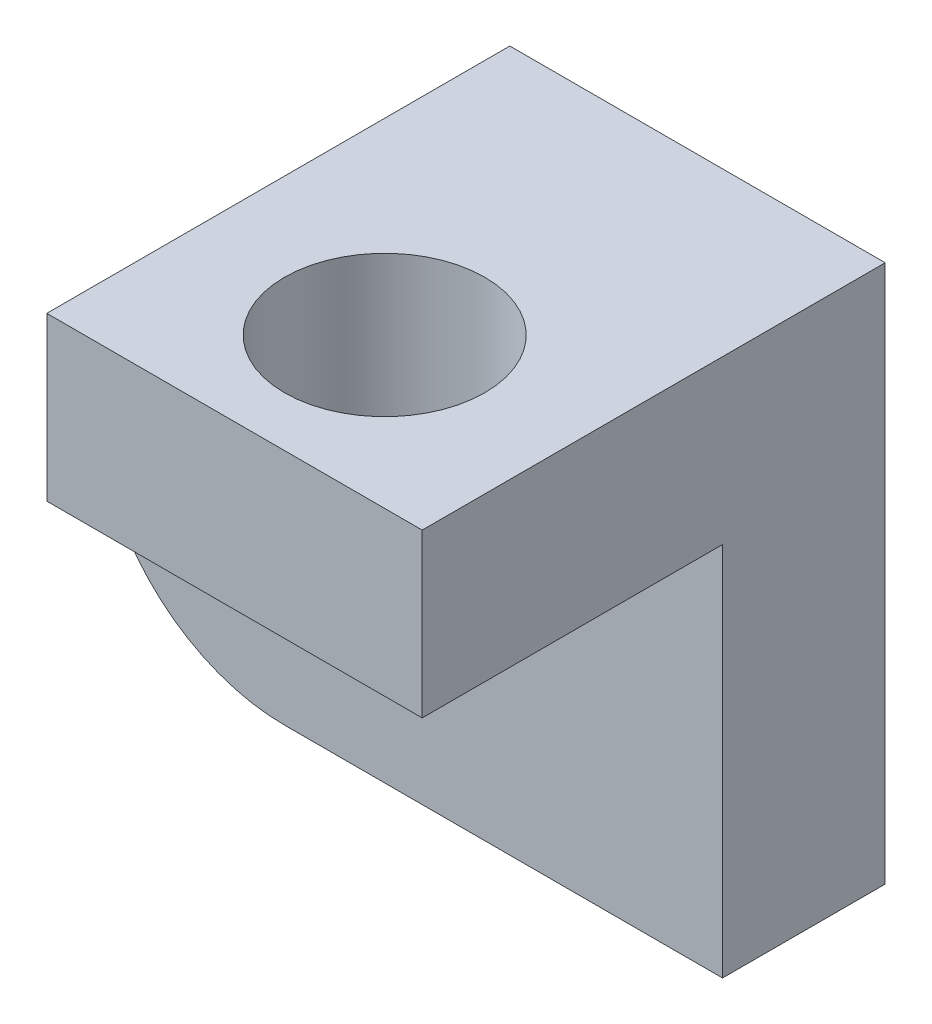
from build123d import *

# Parameters (mm, degrees)
SKETCH1_R           = 6.5
BOSS_EXTRUDE1_DEPTH = 13
SKETCH3_W           = 30
SKETCH3_H           = 13
BOSS_EXTRUDE2_DEPTH = 13
SKETCH6_W           = 30
SKETCH6_H           = 13
BOSS_EXTRUDE4_DEPTH = 24
SKETCH7_R           = 8
CUT_EXTRUDE1_DEPTH  = 13


with BuildPart() as part:
    # Sketch1 → Boss-Extrude1 (new body)
    with BuildSketch(Plane.XY):
        with BuildLine():
            Line((-54.326139095, 0), (-19.326139095, 0))
            Line((-19.326139095, 0), (-19.326139095, 30))
            Line((-19.326139095, 30), (-54.326139095, 30))
            ThreePointArc((-54.326139095, 30), (-69.326139095, 15), (-54.326139095, 0))
        make_face()
        with Locations((-54.326139095, 15)):
            Circle(SKETCH1_R, mode=Mode.SUBTRACT)
    extrude(amount=BOSS_EXTRUDE1_DEPTH)

    # Sketch3 → Boss-Extrude2 (add)
    with BuildSketch(Plane(origin=(0, 30, 0), x_dir=(1, 0, 0), z_dir=(0, 1, 0))):
        with Locations((-34.326139095, -6.5)):
            Rectangle(SKETCH3_W, SKETCH3_H)
    extrude(amount=BOSS_EXTRUDE2_DEPTH)

    # Sketch6 → Boss-Extrude4 (add)
    with BuildSketch(Plane.XY.offset(13)):
        with Locations((-34.326139095, 36.5)):
            Rectangle(SKETCH6_W, SKETCH6_H)
    extrude(amount=BOSS_EXTRUDE4_DEPTH)

    # Sketch7 → Cut-Extrude1 (cut)
    with BuildSketch(Plane.XZ.offset(-30)):
        with Locations((-34.326139095, 25)):
            Circle(SKETCH7_R)
    extrude(amount=-CUT_EXTRUDE1_DEPTH, mode=Mode.SUBTRACT)


solid = part.part
